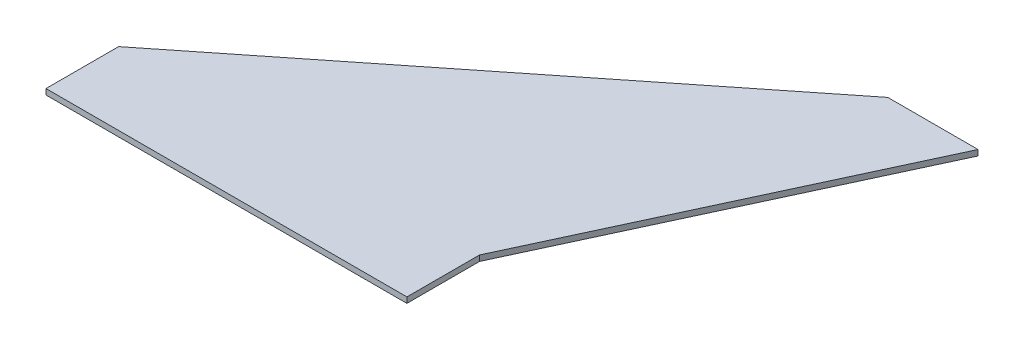
from build123d import *

# Parameters (mm, degrees)
BOSS_EXTRUDE1_DEPTH = 3.175


with BuildPart() as part:
    # Sketch1 → Boss-Extrude1 (new body)
    with BuildSketch(Plane(origin=(0, 0, 0), x_dir=(1, 0, 0), z_dir=(0, 1, 0))):
        Polygon((0, 40.894), (241.3, 232.664), (292.1, 232.664), (203.2, 40.894), (203.2, 0), (0, 0), align=None)
    extrude(amount=BOSS_EXTRUDE1_DEPTH)


solid = part.part
